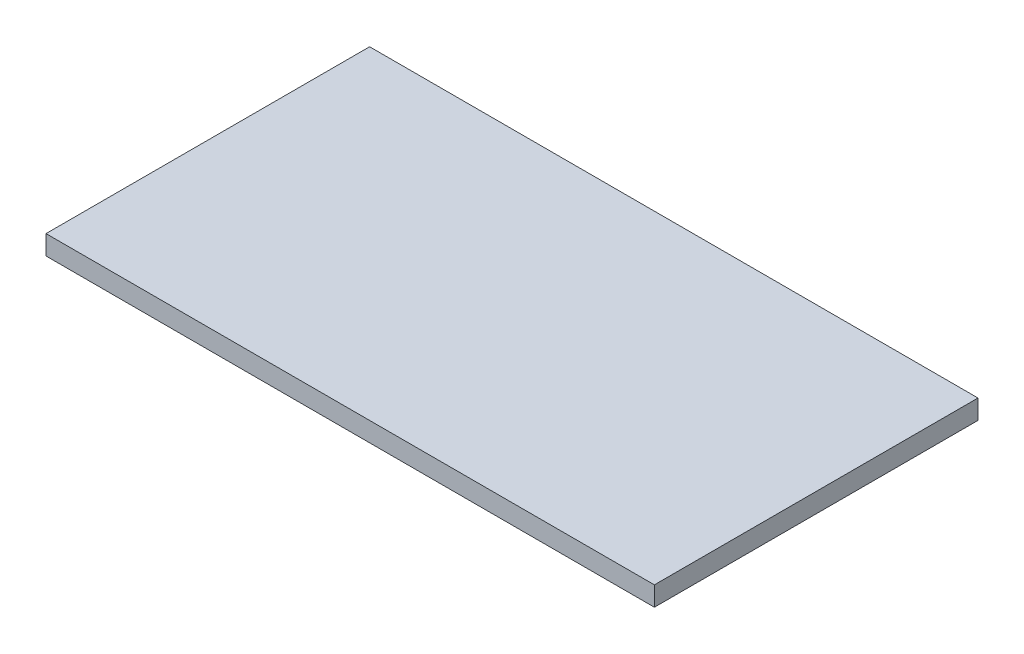
from build123d import *

# Parameters (mm, degrees)
SKETCH1_W           = 564
SKETCH1_H           = 300
BOSS_EXTRUDE1_DEPTH = 18


with BuildPart() as part:
    # Sketch1 → Boss-Extrude1 (new body)
    with BuildSketch(Plane(origin=(0, 0, 0), x_dir=(1, 0, 0), z_dir=(0, 1, 0))):
        Rectangle(SKETCH1_W, SKETCH1_H)
    extrude(amount=BOSS_EXTRUDE1_DEPTH)


solid = part.part
